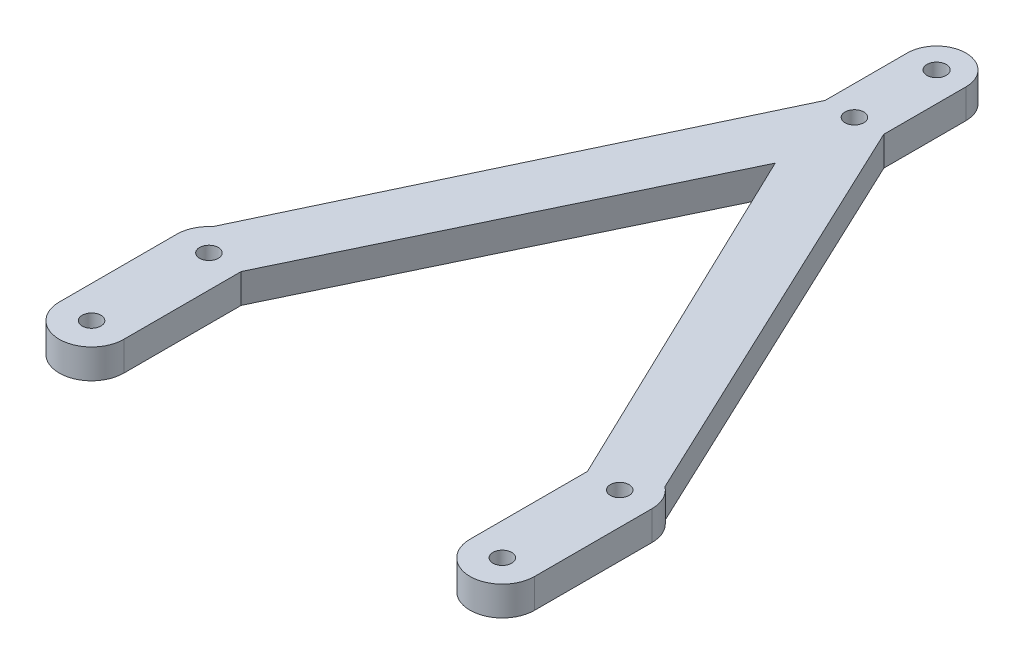
from build123d import *

# Parameters (mm, degrees)
SKETCH_1_R      = 1.6
SKETCH_1_R_2    = 1.634753067
EXTRUDE_1_DEPTH = 5


with BuildPart() as part:
    # 草图1 → 凸台-拉伸1 (new body)
    with BuildSketch(Plane(origin=(0, 0, 0), x_dir=(1, 0, 0), z_dir=(0, 1, 0))):
        with BuildLine():
            Line((-29.5, 11.78850637), (-29.5, -8.21149363))
            ThreePointArc((-29.5, -8.21149363), (-35, -13.71149363), (-40.5, -8.21149363))
            Line((-40.5, -8.21149363), (-40.5, 11.78850637))
            ThreePointArc((-40.5, 11.78850637), (-39.989553993, 14.102453419), (-38.552963292, 15.986893184))
            Line((-38.552963292, 15.986893184), (-5, 86.78850637))
            Line((-5, 86.78850637), (-5, 100.78850637))
            ThreePointArc((-5, 100.78850637), (0, 105.78850637), (5, 100.78850637))
            Line((5, 100.78850637), (5, 86.78850637))
            Line((5, 86.78850637), (38.348099221, 16.152017755))
            ThreePointArc((38.348099221, 16.152017755), (39.932775371, 14.221144268), (40.5, 11.78850637))
            Line((40.5, 11.78850637), (40.5, -8.21149363))
            ThreePointArc((40.5, -8.21149363), (35, -13.71149363), (29.5, -8.21149363))
            Line((29.5, -8.21149363), (29.5, 11.78850637))
            Line((29.5, 11.78850637), (0, 73.28850637))
            Line((0, 73.28850637), (-29.5, 11.78850637))
        make_face()
        with Locations((-35, -8.21149363)):
            Circle(SKETCH_1_R, mode=Mode.SUBTRACT)
        with Locations((-35, 11.78850637)):
            Circle(SKETCH_1_R, mode=Mode.SUBTRACT)
        with Locations((35, 11.78850637)):
            Circle(SKETCH_1_R, mode=Mode.SUBTRACT)
        with Locations((35, -8.21149363)):
            Circle(SKETCH_1_R, mode=Mode.SUBTRACT)
        with Locations((0, 100.78850637)):
            Circle(SKETCH_1_R_2, mode=Mode.SUBTRACT)
        with Locations((0, 86.78850637)):
            Circle(SKETCH_1_R, mode=Mode.SUBTRACT)
    extrude(amount=EXTRUDE_1_DEPTH)


solid = part.part
